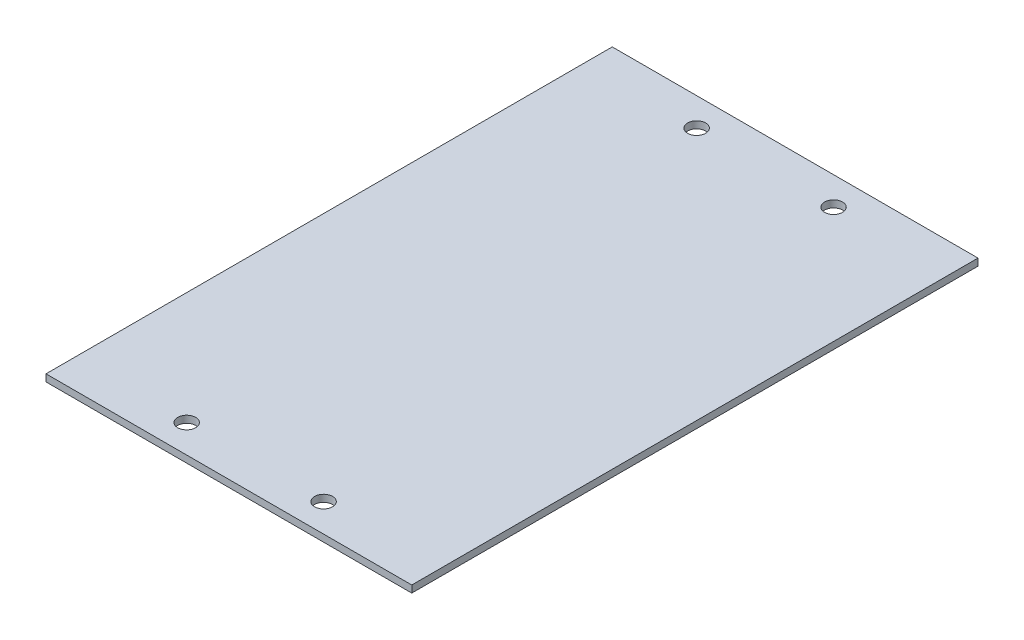
from build123d import *

# Parameters (mm, degrees)
SKETCH3_W           = 330.2
SKETCH3_H           = 6.35
BOSS_EXTRUDE1_DEPTH = 511.175
SKETCH4_R           = 8.128
CUT_EXTRUDE1_DEPTH  = 7.35


with BuildPart() as part:
    # Sketch3 → Boss-Extrude1 (new body)
    with BuildSketch(Plane.XY):
        with Locations((165.1, 3.175)):
            Rectangle(SKETCH3_W, SKETCH3_H)
    extrude(amount=-BOSS_EXTRUDE1_DEPTH)

    # Sketch4 → Cut-Extrude1 (cut, through all)
    with BuildSketch(Plane(origin=(0, 0, 0), x_dir=(1, 0, 0), z_dir=(0, 1, 0))):
        with Locations((101.6, 25.4)):
            Circle(SKETCH4_R)
        with Locations((225.199138423, 25.4)):
            Circle(SKETCH4_R)
        with Locations((225.199138423, 485.775)):
            Circle(SKETCH4_R)
        with Locations((101.6, 485.775)):
            Circle(SKETCH4_R)
    extrude(amount=CUT_EXTRUDE1_DEPTH, mode=Mode.SUBTRACT)


solid = part.part
